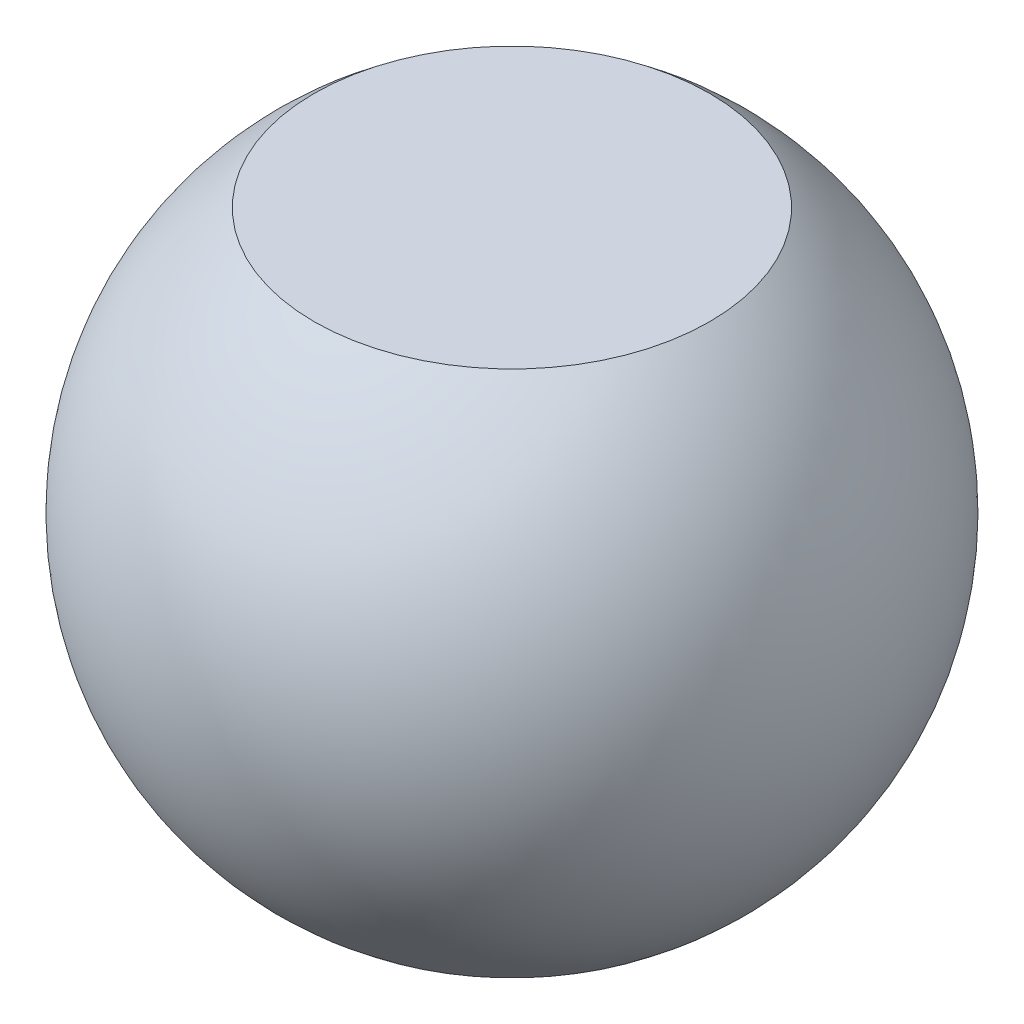
from build123d import *


with BuildPart() as part:
    # Sketch1 → Revolve1 (revolve)
    with BuildSketch(Plane.XY):
        with BuildLine():
            Line((0, 0.3), (0, -0.3))
            Line((0, -0.3), (0.225, -0.3))
            ThreePointArc((0.225, -0.3), (0.375, 0), (0.225, 0.3))
            Line((0.225, 0.3), (0, 0.3))
        make_face()
    revolve(axis=Axis((0, 0.3, 0), (0, -1, 0)))


solid = part.part
